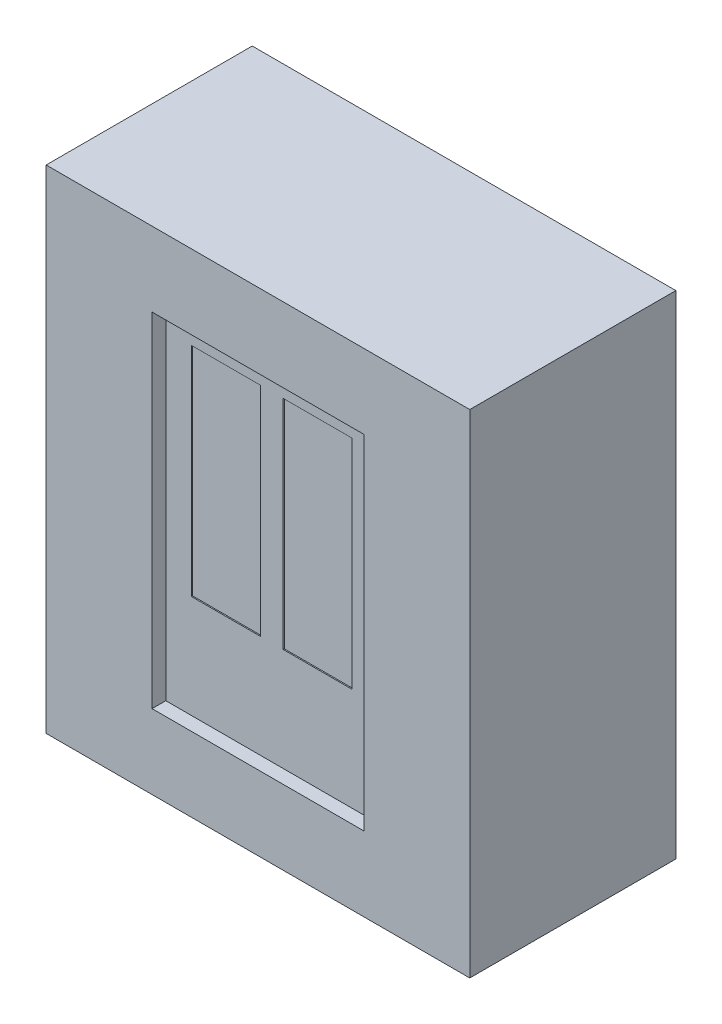
from build123d import *

# Parameters (mm, degrees)
CROQUIS1_W              = 370
CROQUIS1_H              = 430
SALIENTE_EXTRUIR1_DEPTH = 180
CROQUIS2_W              = 185
CROQUIS2_H              = 300
CORTAR_EXTRUIR1_DEPTH   = 12
CROQUIS3_W              = 60
CROQUIS3_H              = 190
CORTAR_EXTRUIR2_DEPTH   = 1


with BuildPart() as part:
    # Croquis1 → Saliente-Extruir1 (new body)
    with BuildSketch(Plane.XY):
        with Locations((185, -215)):
            Rectangle(CROQUIS1_W, CROQUIS1_H)
    extrude(amount=SALIENTE_EXTRUIR1_DEPTH)

    # Croquis2 → Cortar-Extruir1 (cut)
    with BuildSketch(Plane.XY.offset(180)):
        with Locations((185, -215)):
            Rectangle(CROQUIS2_W, CROQUIS2_H)
    extrude(amount=-CORTAR_EXTRUIR1_DEPTH, mode=Mode.SUBTRACT)

    # Croquis3 → Cortar-Extruir2 (cut)
    with BuildSketch(Plane.XY.offset(168)):
        with Locations((145, -180)):
            Rectangle(CROQUIS3_W, CROQUIS3_H)
        with Locations((225, -180)):
            Rectangle(CROQUIS3_W, CROQUIS3_H)
    extrude(amount=-CORTAR_EXTRUIR2_DEPTH, mode=Mode.SUBTRACT)


solid = part.part
